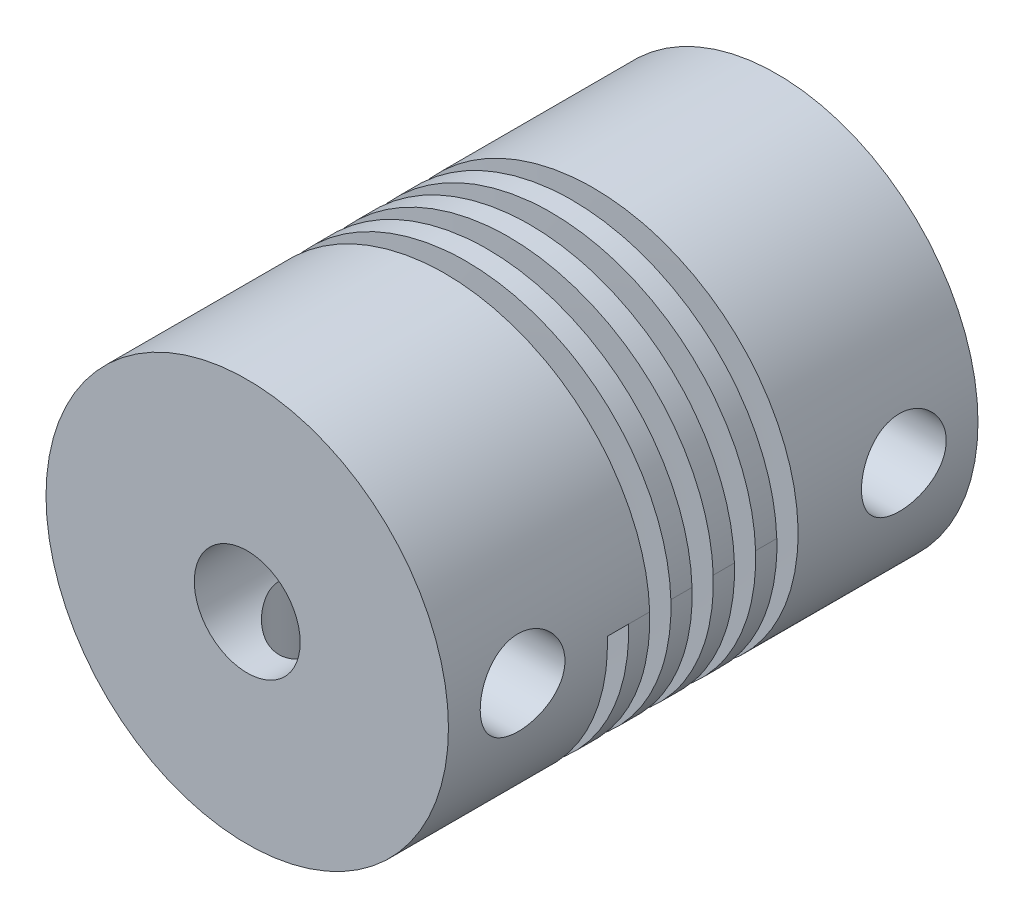
from build123d import *

# Parameters (mm, degrees)
SKETCH1_R           = 9.5
SKETCH1_R_2         = 4
BOSS_EXTRUDE1_DEPTH = 25
SKETCH2_R           = 4
SKETCH2_R_2         = 2.5
BOSS_EXTRUDE2_DEPTH = 12.5
SKETCH3_R           = 2
CUT_EXTRUDE1_DEPTH  = 12.5
CIRPATTERN1_COUNT   = 2
CIRPATTERN1_ANGLE   = 90
SKETCH5_W           = 10
SKETCH5_H           = 1


with BuildPart() as part:
    # Sketch1 → Boss-Extrude1 (new body)
    with BuildSketch(Plane.XY):
        Circle(SKETCH1_R)
        Circle(SKETCH1_R_2, mode=Mode.SUBTRACT)
    extrude(amount=BOSS_EXTRUDE1_DEPTH)

    # Sketch2 → Boss-Extrude2 (add)
    with BuildSketch(Plane.XY.offset(25)):
        Circle(SKETCH2_R)
        Circle(SKETCH2_R_2, mode=Mode.SUBTRACT)
    extrude(amount=-BOSS_EXTRUDE2_DEPTH)

    # Sketch3 → Cut-Extrude1 (cut)
    with BuildSketch(Plane(origin=(0, 0, 0), x_dir=(1, 0, 0), z_dir=(0, 1, 0))):
        with Locations((0, -3.5)):
            Circle(SKETCH3_R)
        with Locations((0, -21.5)):
            Circle(SKETCH3_R)
    cut_extrude1 = extrude(amount=-CUT_EXTRUDE1_DEPTH, mode=Mode.SUBTRACT)

    # CirPattern1: Cut-Extrude1 ×2 about axis
    cirpattern1_axis = Axis((0, 0, 25), (0, 0, 1))
    for i in range(1, CIRPATTERN1_COUNT):
        add(cut_extrude1.rotate(cirpattern1_axis, i * CIRPATTERN1_ANGLE / (CIRPATTERN1_COUNT - 1)), mode=Mode.SUBTRACT)

    # Cut-Sweep1: sweep along a curve in space
    with BuildLine() as cut_sweep1_path:
        add(Edge.make_bspline(
            [(-9.5, 0, 8), (-9.5, -1.235581012, 8.041399753), (-9.00535278, -3.733758663, 8.125123875), (-6.892398623, -6.891428806, 8.249966808), (-3.730139255, -9.005612642, 8.375008894), (0, -9.74725398, 8.499997617), (3.730139255, -9.005371437, 8.625000639), (6.892398623, -6.892393624, 8.749999829), (9.00535278, -3.730140595, 8.875000046), (9.74732361, 3.59e-07, 8.999999988), (9.00535278, 3.730139159, 9.125000003), (6.892398623, 6.892398649, 9.249999999), (3.730139255, 9.005352773, 9.375), (0, 9.747323612, 9.5), (-3.730139255, 9.00535278, 9.625), (-6.892398623, 6.892398623, 9.75), (-9.00535278, 3.730139255, 9.875), (-9.74732361, 0, 10), (-9.00535278, -3.730139255, 10.125), (-6.892398623, -6.892398623, 10.25), (-3.730139255, -9.00535278, 10.375), (0, -9.74732361, 10.5), (3.730139255, -9.00535278, 10.625), (6.892398623, -6.892398623, 10.75), (9.00535278, -3.730139255, 10.875), (9.74732361, 0, 11), (9.00535278, 3.730139255, 11.125), (6.892398623, 6.892398623, 11.25), (3.730139255, 9.00535278, 11.375), (0, 9.74732361, 11.5), (-3.730139255, 9.00535278, 11.625), (-6.892398623, 6.892398623, 11.75), (-9.00535278, 3.730139255, 11.875), (-9.74732361, 0, 12), (-9.00535278, -3.730139255, 12.125), (-6.892398623, -6.892398623, 12.25), (-3.730139255, -9.00535278, 12.375), (0, -9.74732361, 12.5), (3.730139255, -9.00535278, 12.625), (6.892398623, -6.892398623, 12.75), (9.00535278, -3.730139255, 12.875), (9.74732361, 0, 13), (9.00535278, 3.730139255, 13.125), (6.892398623, 6.892398623, 13.25), (3.730139255, 9.00535278, 13.375), (0, 9.74732361, 13.5), (-3.730139255, 9.00535278, 13.625), (-6.892398623, 6.892398623, 13.75), (-9.00535278, 3.730139255, 13.875), (-9.74732361, 0, 14), (-9.00535278, -3.730139255, 14.125), (-6.892398623, -6.892398623, 14.25), (-3.730139255, -9.00535278, 14.375), (0, -9.74732361, 14.5), (3.730139255, -9.00535278, 14.625), (6.892398623, -6.892398623, 14.75), (9.00535278, -3.730139255, 14.875), (9.74732361, 0, 15), (9.00535278, 3.730139255, 15.125), (6.892398623, 6.892398623, 15.25), (3.730139255, 9.00535278, 15.375), (0, 9.747323612, 15.5), (-3.730139255, 9.005352773, 15.625), (-6.892398623, 6.892398649, 15.750000001), (-9.00535278, 3.730139159, 15.874999997), (-9.74732361, 3.59e-07, 16.000000012), (-9.00535278, -3.730140595, 16.124999954), (-6.892398623, -6.892393624, 16.250000171), (-3.730139255, -9.005371437, 16.374999361), (0, -9.74725398, 16.500002383), (3.730139255, -9.005612642, 16.624991106), (6.892398623, -6.891428806, 16.750033192), (9.00535278, -3.733758663, 16.874876125), (9.5, -1.235581012, 16.958600247), (9.5, 0, 17)],
            knots=[0, 0, 0, 0, 0.013888889, 0.027777778, 0.041666667, 0.055555556, 0.069444444, 0.083333333, 0.097222222, 0.111111111, 0.125, 0.138888889, 0.152777778, 0.166666667, 0.180555556, 0.194444444, 0.208333333, 0.222222222, 0.236111111, 0.25, 0.263888889, 0.277777778, 0.291666667, 0.305555556, 0.319444444, 0.333333333, 0.347222222, 0.361111111, 0.375, 0.388888889, 0.402777778, 0.416666667, 0.430555556, 0.444444444, 0.458333333, 0.472222222, 0.486111111, 0.5, 0.513888889, 0.527777778, 0.541666667, 0.555555556, 0.569444444, 0.583333333, 0.597222222, 0.611111111, 0.625, 0.638888889, 0.652777778, 0.666666667, 0.680555556, 0.694444444, 0.708333333, 0.722222222, 0.736111111, 0.75, 0.763888889, 0.777777778, 0.791666667, 0.805555556, 0.819444444, 0.833333333, 0.847222222, 0.861111111, 0.875, 0.888888889, 0.902777778, 0.916666667, 0.930555556, 0.944444444, 0.958333333, 0.972222222, 0.986111111, 1, 1, 1, 1], degree=3))
    # Sketch5 → Cut-Sweep1 (sweep, cut)
    with BuildSketch(Plane(origin=(0, 0, 0), x_dir=(1, 0, 0), z_dir=(0, 1, 0))):
        with Locations((-9.5, -8)):
            Rectangle(SKETCH5_W, SKETCH5_H)
    sweep(path=cut_sweep1_path.line, is_frenet=True, mode=Mode.SUBTRACT)


solid = part.part
